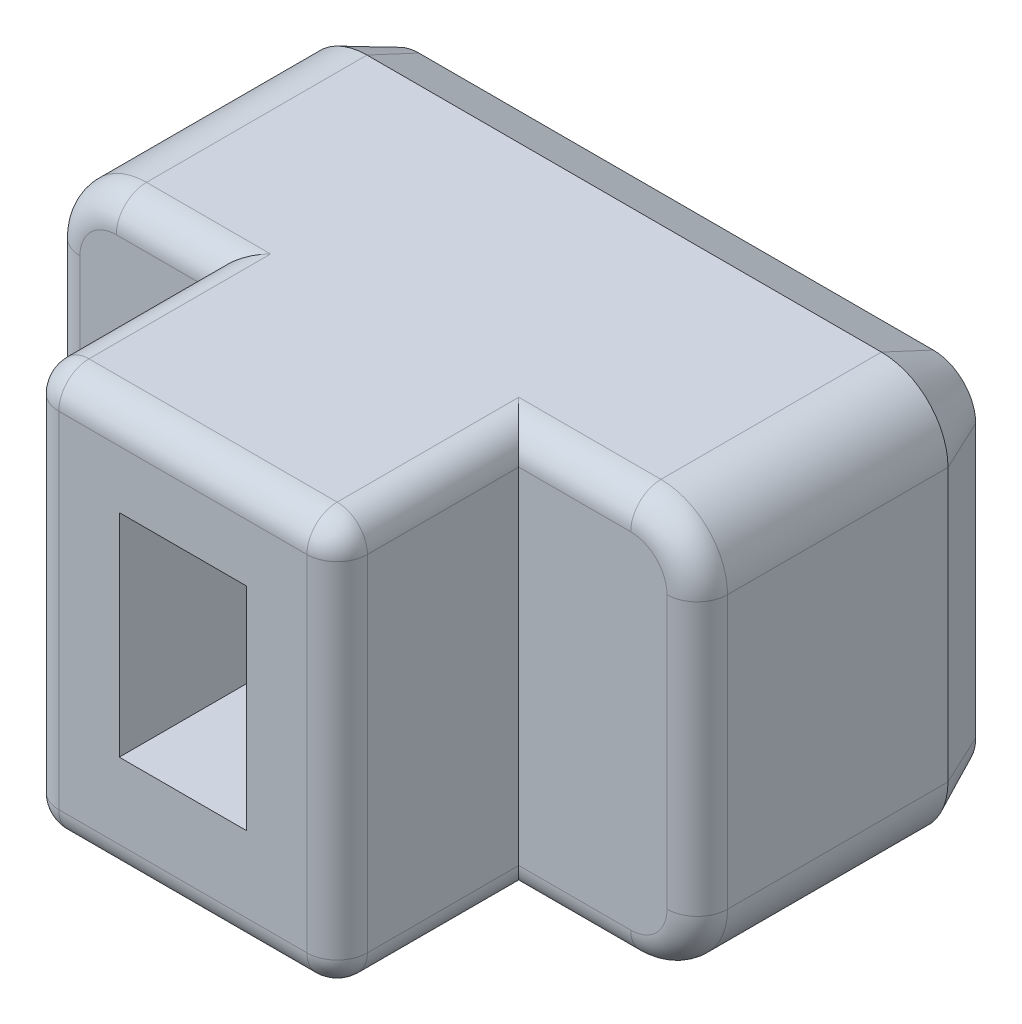
from build123d import *

# Parameters (mm, degrees)
BOSS_EXTRU_1_DEPTH      = 8
ESQUISSE3_W             = 2.1
ESQUISSE3_H             = 3.5
ENL_V_MAT_EXTRU_1_DEPTH = 3
ESQUISSE4_OUTSIDE_W     = 15.69
ESQUISSE4_OUTSIDE_H     = 11.69
ESQUISSE4_OUTSIDE_W_2   = 5.1
ESQUISSE4_OUTSIDE_H_2   = 6.7
ENL_V_MAT_EXTRU_2_DEPTH = 3
CONG_1_R                = 0.5
CHANFREIN1_SIZE         = 0.4
CHANFREIN1_SIZE2        = 0.857802768
ENL_V_MAT_EXTRU_3_DEPTH = 0.2
BOSS_EXTRU_2_DEPTH      = 0.2
BOSS_EXTRU_2_2_DEPTH    = 0.2
BOSS_EXTRU_2_3_DEPTH    = 0.2
BOSS_EXTRU_2_4_DEPTH    = 0.2


with BuildPart() as part:
    # Esquisse2 → Boss.-Extru.1 (new body)
    with BuildSketch(Plane.XY):
        with BuildLine():
            Line((1.1, 0), (9.6, 0))
            ThreePointArc((9.6, 0), (10.377817459, 0.322182541), (10.7, 1.1))
            Line((10.7, 1.1), (10.7, 5.6))
            ThreePointArc((10.7, 5.6), (10.377817459, 6.377817459), (9.6, 6.7))
            Line((9.6, 6.7), (1.1, 6.7))
            ThreePointArc((1.1, 6.7), (0.322182541, 6.377817459), (0, 5.6))
            Line((0, 5.6), (0, 1.1))
            ThreePointArc((0, 1.1), (0.322182541, 0.322182541), (1.1, 0))
        make_face()
    extrude(amount=BOSS_EXTRU_1_DEPTH)

    # Esquisse3 → Enlèv. mat.-Extru.1 (cut)
    with BuildSketch(Plane.XY.offset(8)):
        with Locations((5.2, 3.5)):
            Rectangle(ESQUISSE3_W, ESQUISSE3_H)
    extrude(amount=-ENL_V_MAT_EXTRU_1_DEPTH, mode=Mode.SUBTRACT)

    # Esquisse4 outside → Enlèv. mat.-Extru.2 (cut)
    with BuildSketch(Plane.XY.offset(8)):
        with Locations((5.35, 3.35)):
            Rectangle(ESQUISSE4_OUTSIDE_W, ESQUISSE4_OUTSIDE_H)
        with Locations((5.2, 3.35)):
            Rectangle(ESQUISSE4_OUTSIDE_W_2, ESQUISSE4_OUTSIDE_H_2, mode=Mode.SUBTRACT)
    extrude(amount=-ENL_V_MAT_EXTRU_2_DEPTH, mode=Mode.SUBTRACT)

    # Congé1
    cong_1_edges = [part.edges().sort_by_distance(p)[0] for p in [
        (8.675, 0, 5),
        (10.377817459, 0.322182541, 5),
        (10.7, 3.35, 5),
        (10.377817459, 6.377817459, 5),
        (1.875, 6.7, 5),
        (0.322182541, 6.377817459, 5),
        (1.875, 0, 5),
        (0.322182541, 0.322182541, 5),
        (7.75, 6.7, 6.5),
        (2.65, 6.7, 6.5),
        (7.75, 0, 6.5),
        (2.65, 0, 6.5),
        (2.65, 3.35, 8),
        (5.2, 6.7, 8),
        (7.75, 3.35, 8),
        (5.2, 0, 8),
        (8.675, 6.7, 5),
        (0, 3.35, 5),
    ]]
    fillet(cong_1_edges, radius=CONG_1_R)

    # Chanfrein1
    chanfrein1_edges = [part.edges().sort_by_distance(p)[0] for p in [
        (5.35, 0, 0),
        (10.377817459, 0.322182541, 0),
        (0.322182541, 0.322182541, 0),
        (10.7, 3.35, 0),
        (0, 3.35, 0),
        (10.377817459, 6.377817459, 0),
        (0.322182541, 6.377817459, 0),
        (5.35, 6.7, 0),
    ]]
    chanfrein1_side = [part.faces().sort_by_distance(p)[0] for p in [
        (5.35, 3.35, 0),
    ]]
    chamfer(chanfrein1_edges, length=CHANFREIN1_SIZE, length2=CHANFREIN1_SIZE2, reference=chanfrein1_side[0])

    # Esquisse5 → Enlèv. mat.-Extru.3 (cut)
    with BuildSketch(Plane.XY):
        with BuildLine():
            Line((2.168123449, 5.092998901), (2.042902014, 5.092998901))
            Line((2.042902014, 5.092998901), (1.482284211, 3.15206666))
            add(Edge.make_bspline(
                [(1.482284211, 3.15206666), (1.462716815, 3.083737031), (1.422882264, 2.944634199), (1.364546805, 2.731131974), (1.306291615, 2.508973197), (1.268398379, 2.357595405), (1.249113263, 2.28055426)],
                knots=[0, 0, 0, 0, 0.94534159, 1.924490084, 2.943704635, 4, 4, 4, 4], degree=3))
            Line((1.249113263, 2.28055426), (1.236159321, 2.28055426))
            add(Edge.make_bspline(
                [(1.236159321, 2.28055426), (1.23970058, 2.39113746), (1.246628773, 2.607484758), (1.253710798, 2.924869424), (1.258304849, 3.227857485), (1.25889881, 3.425057435), (1.259188551, 3.521253994)],
                knots=[0, 0, 0, 0, 1.069866814, 2.093109932, 3.069795597, 4, 4, 4, 4], degree=3))
            Line((1.259188551, 3.521253994), (1.259188551, 5.092998901))
            Line((1.259188551, 5.092998901), (0.987875442, 5.092998901))
            Line((0.987875442, 5.092998901), (0.987875442, 1.842998901))
            Line((0.987875442, 1.842998901), (1.379372342, 1.842998901))
            Line((1.379372342, 1.842998901), (1.903287311, 3.681738936))
            add(Edge.make_bspline(
                [(1.903287311, 3.681738936), (1.918789735, 3.737112468), (1.951218656, 3.852946215), (1.99893968, 4.035224749), (2.050531139, 4.232890287), (2.083895434, 4.370403301), (2.101194751, 4.441703507)],
                knots=[0, 0, 0, 0, 0.878607785, 1.837925622, 2.878969022, 4, 4, 4, 4], degree=3))
            Line((2.101194751, 4.441703507), (2.109830712, 4.441703507))
            add(Edge.make_bspline(
                [(2.109830712, 4.441703507), (2.119732435, 4.40189823), (2.138988353, 4.324488762), (2.165926865, 4.211525105), (2.192288217, 4.105896922), (2.219051487, 4.007651048), (2.241906277, 3.915891502), (2.265326085, 3.831614746), (2.286898462, 3.754365879), (2.300994592, 3.705240445), (2.307738152, 3.681738936)],
                knots=[0, 0, 0, 0, 1.253441168, 2.437571641, 3.548775301, 4.580069065, 5.549063513, 6.438240406, 7.252857363, 8, 8, 8, 8], degree=3))
            Line((2.307738152, 3.681738936), (2.831653121, 1.842998901))
            Line((2.831653121, 1.842998901), (3.223150021, 1.842998901))
            Line((3.223150021, 1.842998901), (3.223150021, 5.092998901))
            Line((3.223150021, 5.092998901), (2.951836912, 5.092998901))
            Line((2.951836912, 5.092998901), (2.951836912, 3.521253994))
            add(Edge.make_bspline(
                [(2.951836912, 3.521253994), (2.952129885, 3.426496771), (2.952733659, 3.231215906), (2.957341792, 2.929667607), (2.964438053, 2.610844661), (2.971329306, 2.392576966), (2.974866142, 2.28055426)],
                knots=[0, 0, 0, 0, 0.916288055, 1.888336497, 2.916219559, 4, 4, 4, 4], degree=3))
            Line((2.974866142, 2.28055426), (2.9619122, 2.28055426))
            add(Edge.make_bspline(
                [(2.9619122, 2.28055426), (2.942035311, 2.3609874), (2.90346632, 2.517059361), (2.843001072, 2.742420359), (2.787144143, 2.953047615), (2.747725738, 3.087373387), (2.728741252, 3.15206666)],
                knots=[0, 0, 0, 0, 1.101929995, 2.138178037, 3.103319075, 4, 4, 4, 4], degree=3))
            Line((2.728741252, 3.15206666), (2.168123449, 5.092998901))
        make_face()
        Polygon((4.068754538, 4.736045845), (5.210140721, 4.736045845), (5.210140721, 5.092998901), (3.79744143, 5.092998901), (3.79744143, 1.842998901), (5.14896933, 1.842998901), (5.14896933, 2.199951957), (4.068754538, 2.199951957), (4.068754538, 3.249221222), (5.028785539, 3.249221222), (5.028785539, 3.606174277), (4.068754538, 3.606174277), align=None)
        with BuildLine():
            add(Edge.make_bspline(
                [(6.829383414, 3.65511139), (6.897484733, 3.800276067), (7.035084874, 4.093584337), (7.167137408, 4.389431923), (7.233834255, 4.538858068)],
                knots=[0, 0, 0, 0, 0.989843741, 2, 2, 2, 2], degree=3))
            Line((7.233834255, 4.538858068), (7.243909543, 4.538858068))
            add(Edge.make_bspline(
                [(7.243909543, 4.538858068), (7.237433848, 4.379354193), (7.224359459, 4.057316837), (7.223003831, 3.73501637), (7.22231964, 3.572350097)],
                knots=[0, 0, 0, 0, 0.990592384, 2, 2, 2, 2], degree=3))
            Line((7.22231964, 3.572350097), (7.22231964, 1.842998901))
            Line((7.22231964, 1.842998901), (7.493632749, 1.842998901))
            Line((7.493632749, 1.842998901), (7.493632749, 5.092998901))
            Line((7.493632749, 5.092998901), (7.223758967, 5.092998901))
            Line((7.223758967, 5.092998901), (6.350087577, 3.280886412))
            add(Edge.make_bspline(
                [(6.350087577, 3.280886412), (6.313243704, 3.203468985), (6.240839341, 3.05133081), (6.136787854, 2.826516739), (6.038501858, 2.609481775), (5.976194754, 2.467012598), (5.945636735, 2.397139734)],
                knots=[0, 0, 0, 0, 1.058533243, 2.080194624, 3.058446861, 4, 4, 4, 4], degree=3))
            Line((5.945636735, 2.397139734), (5.935561447, 2.397139734))
            add(Edge.make_bspline(
                [(5.935561447, 2.397139734), (5.938933402, 2.474135012), (5.945959162, 2.634561327), (5.951760591, 2.884570568), (5.956476184, 3.153248256), (5.956921306, 3.338456967), (5.95715135, 3.43417472)],
                knots=[0, 0, 0, 0, 0.891510562, 1.857539279, 2.892754421, 4, 4, 4, 4], degree=3))
            Line((5.95715135, 3.43417472), (5.95715135, 5.092998901))
            Line((5.95715135, 5.092998901), (5.685838241, 5.092998901))
            Line((5.685838241, 5.092998901), (5.685838241, 1.842998901))
            Line((5.685838241, 1.842998901), (5.955712023, 1.842998901))
            Line((5.955712023, 1.842998901), (6.829383414, 3.65511139))
        make_face()
        with BuildLine():
            add(Edge.make_bspline(
                [(8.895537089, 4.801535216), (8.915219879, 4.800857533), (8.953518367, 4.799538908), (9.009701137, 4.792884309), (9.062052462, 4.778705144), (9.111285838, 4.760847877), (9.157282553, 4.738387582), (9.199466626, 4.710928984), (9.239136867, 4.679499925), (9.288011188, 4.631245384), (9.342627988, 4.560278971), (9.394800828, 4.461246147), (9.435765626, 4.349222362), (9.453487169, 4.269237412), (9.462631864, 4.227963471)],
                knots=[0, 0, 0, 0, 0.801296721, 1.559151615, 2.295391855, 3.002525829, 3.687835526, 4.372797615, 5.046541552, 5.743635125, 7.162946003, 8.669483245, 10.281382281, 12, 12, 12, 12], degree=3))
            add(Edge.make_bspline(
                [(9.462631864, 4.227963471), (9.467864133, 4.199958703), (9.478899359, 4.14089467), (9.486943157, 4.048899291), (9.492144546, 3.953836007), (9.4926219, 3.890209448), (9.492857727, 3.858776137)],
                knots=[0, 0, 0, 0, 0.920956141, 1.942361529, 2.983468673, 4, 4, 4, 4], degree=3))
            Line((9.492857727, 3.858776137), (9.492857727, 1.842998901))
            Line((9.492857727, 1.842998901), (9.764170836, 1.842998901))
            Line((9.764170836, 1.842998901), (9.764170836, 3.849420513))
            add(Edge.make_bspline(
                [(9.764170836, 3.849420513), (9.763643527, 3.888286271), (9.762565603, 3.967735616), (9.757319383, 4.087113931), (9.746145489, 4.204567993), (9.734518648, 4.281022908), (9.728907329, 4.317921399)],
                knots=[0, 0, 0, 0, 0.9916782, 2.027187599, 3.047885936, 4, 4, 4, 4], degree=3))
            add(Edge.make_bspline(
                [(9.728907329, 4.317921399), (9.716988787, 4.376055703), (9.69380229, 4.489150987), (9.647268708, 4.6243645), (9.602178335, 4.72438105), (9.563429824, 4.793683365), (9.519141906, 4.857198651), (9.470757667, 4.915909332), (9.417625529, 4.969668847), (9.358339988, 5.016253089), (9.294404171, 5.056922194), (9.225590401, 5.09164329), (9.151134606, 5.120422192), (9.069918236, 5.138924719), (8.983040709, 5.152014931), (8.922938311, 5.152962099), (8.891938772, 5.153450628)],
                knots=[0, 0, 0, 0, 1.909769179, 3.715291546, 4.589971324, 5.4409235, 6.26815294, 7.080272725, 7.888783235, 8.697183003, 9.5030315, 10.325339926, 11.176221958, 12.066290597, 13.002633812, 14, 14, 14, 14], degree=3))
            add(Edge.make_bspline(
                [(8.891938772, 5.153450628), (8.862404623, 5.152766223), (8.804808402, 5.151431525), (8.721259213, 5.14091316), (8.643543118, 5.121789534), (8.571183103, 5.09663041), (8.50384461, 5.065180331), (8.442539057, 5.026233064), (8.385133289, 4.983288551), (8.333268503, 4.933812682), (8.285866682, 4.879673356), (8.241987721, 4.821184698), (8.204303967, 4.756820957), (8.158696591, 4.664294036), (8.111390111, 4.538601614), (8.085984255, 4.433146591), (8.072961802, 4.379092789)],
                knots=[0, 0, 0, 0, 1.002214029, 1.954474501, 2.850948524, 3.713509908, 4.551120705, 5.366639331, 6.174276787, 6.980558973, 7.793920946, 8.614584339, 9.457912683, 10.32081979, 12.114137478, 14, 14, 14, 14], degree=3))
            add(Edge.make_bspline(
                [(8.072961802, 4.379092789), (8.065486672, 4.337188055), (8.050086358, 4.250855632), (8.03672827, 4.118337497), (8.028825932, 3.983616832), (8.027539306, 3.893810648), (8.026903343, 3.849420513)],
                knots=[0, 0, 0, 0, 0.959084698, 1.975912901, 2.999517693, 4, 4, 4, 4], degree=3))
            Line((8.026903343, 3.849420513), (8.026903343, 1.842998901))
            Line((8.026903343, 1.842998901), (8.298216452, 1.842998901))
            Line((8.298216452, 1.842998901), (8.298216452, 3.858776137))
            add(Edge.make_bspline(
                [(8.298216452, 3.858776137), (8.298838888, 3.895734077), (8.300101257, 3.97068887), (8.308216446, 4.082588233), (8.32032586, 4.191289529), (8.335561082, 4.260923658), (8.342835584, 4.294172506)],
                knots=[0, 0, 0, 0, 1.011180969, 2.050786951, 3.069291338, 4, 4, 4, 4], degree=3))
            add(Edge.make_bspline(
                [(8.342835584, 4.294172506), (8.353160666, 4.33167579), (8.373103978, 4.404114889), (8.417453259, 4.503991276), (8.470930582, 4.59181397), (8.534434265, 4.666844122), (8.608337891, 4.728006395), (8.694457041, 4.771577585), (8.791686949, 4.796814382), (8.860123138, 4.799925364), (8.895537089, 4.801535216)],
                knots=[0, 0, 0, 0, 1.140660192, 2.20323094, 3.196092102, 4.150156216, 5.076259019, 5.992779707, 6.961315602, 8, 8, 8, 8], degree=3))
        make_face()
    extrude(amount=ENL_V_MAT_EXTRU_3_DEPTH, mode=Mode.SUBTRACT)


with BuildPart() as body_2:
    # Esquisse5_4 → Boss.-Extru.2 (new body)
    with BuildSketch(Plane.XY):
        with BuildLine():
            Line((2.168123449, 5.092998901), (2.042902014, 5.092998901))
            Line((2.042902014, 5.092998901), (1.482284211, 3.15206666))
            add(Edge.make_bspline(
                [(1.482284211, 3.15206666), (1.462716815, 3.083737031), (1.422882264, 2.944634199), (1.364546805, 2.731131974), (1.306291615, 2.508973197), (1.268398379, 2.357595405), (1.249113263, 2.28055426)],
                knots=[0, 0, 0, 0, 0.94534159, 1.924490084, 2.943704635, 4, 4, 4, 4], degree=3))
            Line((1.249113263, 2.28055426), (1.236159321, 2.28055426))
            add(Edge.make_bspline(
                [(1.236159321, 2.28055426), (1.23970058, 2.39113746), (1.246628773, 2.607484758), (1.253710798, 2.924869424), (1.258304849, 3.227857485), (1.25889881, 3.425057435), (1.259188551, 3.521253994)],
                knots=[0, 0, 0, 0, 1.069866814, 2.093109932, 3.069795597, 4, 4, 4, 4], degree=3))
            Line((1.259188551, 3.521253994), (1.259188551, 5.092998901))
            Line((1.259188551, 5.092998901), (0.987875442, 5.092998901))
            Line((0.987875442, 5.092998901), (0.987875442, 1.842998901))
            Line((0.987875442, 1.842998901), (1.379372342, 1.842998901))
            Line((1.379372342, 1.842998901), (1.903287311, 3.681738936))
            add(Edge.make_bspline(
                [(1.903287311, 3.681738936), (1.918789735, 3.737112468), (1.951218656, 3.852946215), (1.99893968, 4.035224749), (2.050531139, 4.232890287), (2.083895434, 4.370403301), (2.101194751, 4.441703507)],
                knots=[0, 0, 0, 0, 0.878607785, 1.837925622, 2.878969022, 4, 4, 4, 4], degree=3))
            Line((2.101194751, 4.441703507), (2.109830712, 4.441703507))
            add(Edge.make_bspline(
                [(2.109830712, 4.441703507), (2.119732435, 4.40189823), (2.138988353, 4.324488762), (2.165926865, 4.211525105), (2.192288217, 4.105896922), (2.219051487, 4.007651048), (2.241906277, 3.915891502), (2.265326085, 3.831614746), (2.286898462, 3.754365879), (2.300994592, 3.705240445), (2.307738152, 3.681738936)],
                knots=[0, 0, 0, 0, 1.253441168, 2.437571641, 3.548775301, 4.580069065, 5.549063513, 6.438240406, 7.252857363, 8, 8, 8, 8], degree=3))
            Line((2.307738152, 3.681738936), (2.831653121, 1.842998901))
            Line((2.831653121, 1.842998901), (3.223150021, 1.842998901))
            Line((3.223150021, 1.842998901), (3.223150021, 5.092998901))
            Line((3.223150021, 5.092998901), (2.951836912, 5.092998901))
            Line((2.951836912, 5.092998901), (2.951836912, 3.521253994))
            add(Edge.make_bspline(
                [(2.951836912, 3.521253994), (2.952129885, 3.426496771), (2.952733659, 3.231215906), (2.957341792, 2.929667607), (2.964438053, 2.610844661), (2.971329306, 2.392576966), (2.974866142, 2.28055426)],
                knots=[0, 0, 0, 0, 0.916288055, 1.888336497, 2.916219559, 4, 4, 4, 4], degree=3))
            Line((2.974866142, 2.28055426), (2.9619122, 2.28055426))
            add(Edge.make_bspline(
                [(2.9619122, 2.28055426), (2.942035311, 2.3609874), (2.90346632, 2.517059361), (2.843001072, 2.742420359), (2.787144143, 2.953047615), (2.747725738, 3.087373387), (2.728741252, 3.15206666)],
                knots=[0, 0, 0, 0, 1.101929995, 2.138178037, 3.103319075, 4, 4, 4, 4], degree=3))
            Line((2.728741252, 3.15206666), (2.168123449, 5.092998901))
        make_face()
    extrude(amount=-BOSS_EXTRU_2_DEPTH)


with BuildPart() as body_3:
    # Esquisse5_4 → Boss.-Extru.2 2 (new body)
    with BuildSketch(Plane.XY):
        Polygon((4.068754538, 4.736045845), (5.210140721, 4.736045845), (5.210140721, 5.092998901), (3.79744143, 5.092998901), (3.79744143, 1.842998901), (5.14896933, 1.842998901), (5.14896933, 2.199951957), (4.068754538, 2.199951957), (4.068754538, 3.249221222), (5.028785539, 3.249221222), (5.028785539, 3.606174277), (4.068754538, 3.606174277), align=None)
    extrude(amount=-BOSS_EXTRU_2_2_DEPTH)


with BuildPart() as body_4:
    # Esquisse5_4 → Boss.-Extru.2 3 (new body)
    with BuildSketch(Plane.XY):
        with BuildLine():
            add(Edge.make_bspline(
                [(6.829383414, 3.65511139), (6.897484733, 3.800276067), (7.035084874, 4.093584337), (7.167137408, 4.389431923), (7.233834255, 4.538858068)],
                knots=[0, 0, 0, 0, 0.989843741, 2, 2, 2, 2], degree=3))
            Line((7.233834255, 4.538858068), (7.243909543, 4.538858068))
            add(Edge.make_bspline(
                [(7.243909543, 4.538858068), (7.237433848, 4.379354193), (7.224359459, 4.057316837), (7.223003831, 3.73501637), (7.22231964, 3.572350097)],
                knots=[0, 0, 0, 0, 0.990592384, 2, 2, 2, 2], degree=3))
            Line((7.22231964, 3.572350097), (7.22231964, 1.842998901))
            Line((7.22231964, 1.842998901), (7.493632749, 1.842998901))
            Line((7.493632749, 1.842998901), (7.493632749, 5.092998901))
            Line((7.493632749, 5.092998901), (7.223758967, 5.092998901))
            Line((7.223758967, 5.092998901), (6.350087577, 3.280886412))
            add(Edge.make_bspline(
                [(6.350087577, 3.280886412), (6.313243704, 3.203468985), (6.240839341, 3.05133081), (6.136787854, 2.826516739), (6.038501858, 2.609481775), (5.976194754, 2.467012598), (5.945636735, 2.397139734)],
                knots=[0, 0, 0, 0, 1.058533243, 2.080194624, 3.058446861, 4, 4, 4, 4], degree=3))
            Line((5.945636735, 2.397139734), (5.935561447, 2.397139734))
            add(Edge.make_bspline(
                [(5.935561447, 2.397139734), (5.938933402, 2.474135012), (5.945959162, 2.634561327), (5.951760591, 2.884570568), (5.956476184, 3.153248256), (5.956921306, 3.338456967), (5.95715135, 3.43417472)],
                knots=[0, 0, 0, 0, 0.891510562, 1.857539279, 2.892754421, 4, 4, 4, 4], degree=3))
            Line((5.95715135, 3.43417472), (5.95715135, 5.092998901))
            Line((5.95715135, 5.092998901), (5.685838241, 5.092998901))
            Line((5.685838241, 5.092998901), (5.685838241, 1.842998901))
            Line((5.685838241, 1.842998901), (5.955712023, 1.842998901))
            Line((5.955712023, 1.842998901), (6.829383414, 3.65511139))
        make_face()
    extrude(amount=-BOSS_EXTRU_2_3_DEPTH)


with BuildPart() as body_5:
    # Esquisse5_4 → Boss.-Extru.2 4 (new body)
    with BuildSketch(Plane.XY):
        with BuildLine():
            add(Edge.make_bspline(
                [(8.895537089, 4.801535216), (8.915219879, 4.800857533), (8.953518367, 4.799538908), (9.009701137, 4.792884309), (9.062052462, 4.778705144), (9.111285838, 4.760847877), (9.157282553, 4.738387582), (9.199466626, 4.710928984), (9.239136867, 4.679499925), (9.288011188, 4.631245384), (9.342627988, 4.560278971), (9.394800828, 4.461246147), (9.435765626, 4.349222362), (9.453487169, 4.269237412), (9.462631864, 4.227963471)],
                knots=[0, 0, 0, 0, 0.801296721, 1.559151615, 2.295391855, 3.002525829, 3.687835526, 4.372797615, 5.046541552, 5.743635125, 7.162946003, 8.669483245, 10.281382281, 12, 12, 12, 12], degree=3))
            add(Edge.make_bspline(
                [(9.462631864, 4.227963471), (9.467864133, 4.199958703), (9.478899359, 4.14089467), (9.486943157, 4.048899291), (9.492144546, 3.953836007), (9.4926219, 3.890209448), (9.492857727, 3.858776137)],
                knots=[0, 0, 0, 0, 0.920956141, 1.942361529, 2.983468673, 4, 4, 4, 4], degree=3))
            Line((9.492857727, 3.858776137), (9.492857727, 1.842998901))
            Line((9.492857727, 1.842998901), (9.764170836, 1.842998901))
            Line((9.764170836, 1.842998901), (9.764170836, 3.849420513))
            add(Edge.make_bspline(
                [(9.764170836, 3.849420513), (9.763643527, 3.888286271), (9.762565603, 3.967735616), (9.757319383, 4.087113931), (9.746145489, 4.204567993), (9.734518648, 4.281022908), (9.728907329, 4.317921399)],
                knots=[0, 0, 0, 0, 0.9916782, 2.027187599, 3.047885936, 4, 4, 4, 4], degree=3))
            add(Edge.make_bspline(
                [(9.728907329, 4.317921399), (9.716988787, 4.376055703), (9.69380229, 4.489150987), (9.647268708, 4.6243645), (9.602178335, 4.72438105), (9.563429824, 4.793683365), (9.519141906, 4.857198651), (9.470757667, 4.915909332), (9.417625529, 4.969668847), (9.358339988, 5.016253089), (9.294404171, 5.056922194), (9.225590401, 5.09164329), (9.151134606, 5.120422192), (9.069918236, 5.138924719), (8.983040709, 5.152014931), (8.922938311, 5.152962099), (8.891938772, 5.153450628)],
                knots=[0, 0, 0, 0, 1.909769179, 3.715291546, 4.589971324, 5.4409235, 6.26815294, 7.080272725, 7.888783235, 8.697183003, 9.5030315, 10.325339926, 11.176221958, 12.066290597, 13.002633812, 14, 14, 14, 14], degree=3))
            add(Edge.make_bspline(
                [(8.891938772, 5.153450628), (8.862404623, 5.152766223), (8.804808402, 5.151431525), (8.721259213, 5.14091316), (8.643543118, 5.121789534), (8.571183103, 5.09663041), (8.50384461, 5.065180331), (8.442539057, 5.026233064), (8.385133289, 4.983288551), (8.333268503, 4.933812682), (8.285866682, 4.879673356), (8.241987721, 4.821184698), (8.204303967, 4.756820957), (8.158696591, 4.664294036), (8.111390111, 4.538601614), (8.085984255, 4.433146591), (8.072961802, 4.379092789)],
                knots=[0, 0, 0, 0, 1.002214029, 1.954474501, 2.850948524, 3.713509908, 4.551120705, 5.366639331, 6.174276787, 6.980558973, 7.793920946, 8.614584339, 9.457912683, 10.32081979, 12.114137478, 14, 14, 14, 14], degree=3))
            add(Edge.make_bspline(
                [(8.072961802, 4.379092789), (8.065486672, 4.337188055), (8.050086358, 4.250855632), (8.03672827, 4.118337497), (8.028825932, 3.983616832), (8.027539306, 3.893810648), (8.026903343, 3.849420513)],
                knots=[0, 0, 0, 0, 0.959084698, 1.975912901, 2.999517693, 4, 4, 4, 4], degree=3))
            Line((8.026903343, 3.849420513), (8.026903343, 1.842998901))
            Line((8.026903343, 1.842998901), (8.298216452, 1.842998901))
            Line((8.298216452, 1.842998901), (8.298216452, 3.858776137))
            add(Edge.make_bspline(
                [(8.298216452, 3.858776137), (8.298838888, 3.895734077), (8.300101257, 3.97068887), (8.308216446, 4.082588233), (8.32032586, 4.191289529), (8.335561082, 4.260923658), (8.342835584, 4.294172506)],
                knots=[0, 0, 0, 0, 1.011180969, 2.050786951, 3.069291338, 4, 4, 4, 4], degree=3))
            add(Edge.make_bspline(
                [(8.342835584, 4.294172506), (8.353160666, 4.33167579), (8.373103978, 4.404114889), (8.417453259, 4.503991276), (8.470930582, 4.59181397), (8.534434265, 4.666844122), (8.608337891, 4.728006395), (8.694457041, 4.771577585), (8.791686949, 4.796814382), (8.860123138, 4.799925364), (8.895537089, 4.801535216)],
                knots=[0, 0, 0, 0, 1.140660192, 2.20323094, 3.196092102, 4.150156216, 5.076259019, 5.992779707, 6.961315602, 8, 8, 8, 8], degree=3))
        make_face()
    extrude(amount=-BOSS_EXTRU_2_4_DEPTH)


solid = Compound([part.part, body_2.part, body_3.part, body_4.part, body_5.part])
